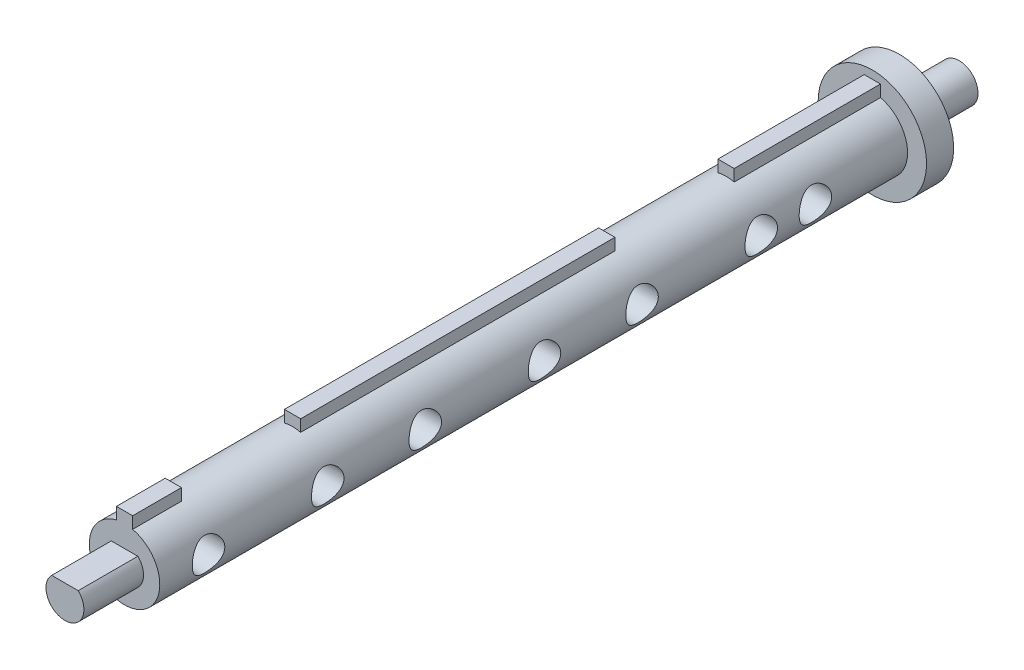
from build123d import *

# Parameters (mm, degrees)
EXTRUDE_1_DEPTH     = 143
SKETCH_2_R          = 3.5
EXTRUDE_2_DEPTH     = 11
SKETCH_3_R          = 3.5
EXTRUDE_3_DEPTH     = 11
CUT_EXTRUDE_1_DEPTH = 11
CUT_EXTRUDE_2_DEPTH = 11
SKETCH_7_R          = 3
CUT_EXTRUDE_3_DEPTH = 10
SKETCH_9_R          = 10
EXTRUDE_4_DEPTH     = 5
SKETCH_10_W         = 22
SKETCH_10_H         = 2.17544468
CUT_EXTRUDE_4_DEPTH = 10
EXTRUDE_5_DEPTH     = 22
SKETCH_13_W         = 22
SKETCH_13_H         = 2.17544468
CUT_EXTRUDE_5_DEPTH = 22
EXTRUDE_6_DEPTH     = 22


with BuildPart() as part:
    # 草图1 → 凸台-拉伸1 (new body)
    with BuildSketch(Plane.XY):
        with BuildLine():
            Line((-1.5, 6.32455532), (-1.5, 8.5))
            Line((-1.5, 8.5), (1.5, 8.5))
            Line((1.5, 8.5), (1.5, 6.32455532))
            ThreePointArc((1.5, 6.32455532), (0, -6.5), (-1.5, 6.32455532))
        make_face()
    extrude(amount=EXTRUDE_1_DEPTH)

    # 草图2 → 凸台-拉伸2 (add)
    with BuildSketch(Plane.XY.offset(143)):
        Circle(SKETCH_2_R)
    extrude(amount=EXTRUDE_2_DEPTH)

    # 草图3 → 凸台-拉伸3 (add)
    with BuildSketch(Plane(origin=(0, 0, 0), x_dir=(-1, 0, 0), z_dir=(0, 0, -1))):
        Circle(SKETCH_3_R)
    extrude(amount=EXTRUDE_3_DEPTH)

    # 草图4 → 切除-拉伸1 (cut)
    with BuildSketch(Plane(origin=(0, 0, -11), x_dir=(-1, 0, 0), z_dir=(0, 0, -1))):
        with BuildLine():
            Line((-2.449489743, -2.5), (2.449489743, -2.5))
            ThreePointArc((2.449489743, -2.5), (0, -3.5), (-2.449489743, -2.5))
        make_face()
    extrude(amount=-CUT_EXTRUDE_1_DEPTH, mode=Mode.SUBTRACT)

    # 草图5 → 切除-拉伸2 (cut)
    with BuildSketch(Plane.XY.offset(154)):
        with BuildLine():
            Line((-2.449489743, 2.5), (2.449489743, 2.5))
            ThreePointArc((2.449489743, 2.5), (0, 3.5), (-2.449489743, 2.5))
        make_face()
    extrude(amount=-CUT_EXTRUDE_2_DEPTH, mode=Mode.SUBTRACT)

    # 草图7 → 切除-拉伸3 (cut, symmetric)
    with BuildSketch(Plane(origin=(0, 0, 0), x_dir=(0, 0, -1), z_dir=(1, 0, 0))):
        with Locations((-134, 0)):
            Circle(SKETCH_7_R)
        with Locations((-112, 0)):
            Circle(SKETCH_7_R)
        with Locations((-94, 0)):
            Circle(SKETCH_7_R)
        with Locations((-72, 0)):
            Circle(SKETCH_7_R)
        with Locations((-54, 0)):
            Circle(SKETCH_7_R)
        with Locations((-32, 0)):
            Circle(SKETCH_7_R)
        with Locations((-22, 0)):
            Circle(SKETCH_7_R)
    extrude(amount=CUT_EXTRUDE_3_DEPTH, both=True, mode=Mode.SUBTRACT)

    # 草图9 → 凸台-拉伸4 (add)
    with BuildSketch(Plane(origin=(0, 0, 0), x_dir=(-1, 0, 0), z_dir=(0, 0, -1))):
        Circle(SKETCH_9_R)
    extrude(amount=-EXTRUDE_4_DEPTH)

    # 草图10 → 切除-拉伸4 (cut)
    with BuildSketch(Plane(origin=(1.5, 0, 0), x_dir=(0, 0, -1), z_dir=(1, 0, 0))):
        with Locations((-123, 7.41227766)):
            Rectangle(SKETCH_10_W, SKETCH_10_H)
    extrude(amount=-CUT_EXTRUDE_4_DEPTH, mode=Mode.SUBTRACT)

    # 草图12 → 凸台-拉伸5 (add)
    with BuildSketch(Plane.XY.offset(112)):
        with BuildLine():
            Line((-4.575223176, 4.61706973), (4.575223176, 4.61706973))
            ThreePointArc((4.575223176, 4.61706973), (0, 6.5), (-4.575223176, 4.61706973))
        make_face()
    extrude(amount=EXTRUDE_5_DEPTH)

    # 草图13 → 切除-拉伸5 (cut)
    with BuildSketch(Plane(origin=(1.5, 0, 0), x_dir=(0, 0, -1), z_dir=(1, 0, 0))):
        with Locations((-43, 7.41227766)):
            Rectangle(SKETCH_13_W, SKETCH_13_H)
    extrude(amount=-CUT_EXTRUDE_5_DEPTH, mode=Mode.SUBTRACT)

    # 草图14 → 凸台-拉伸6 (add)
    with BuildSketch(Plane.XY.offset(32)):
        with BuildLine():
            Line((-4.074115353, 5.064739292), (4.074115353, 5.064739292))
            ThreePointArc((4.074115353, 5.064739292), (0, 6.5), (-4.074115353, 5.064739292))
        make_face()
    extrude(amount=EXTRUDE_6_DEPTH)


solid = part.part
